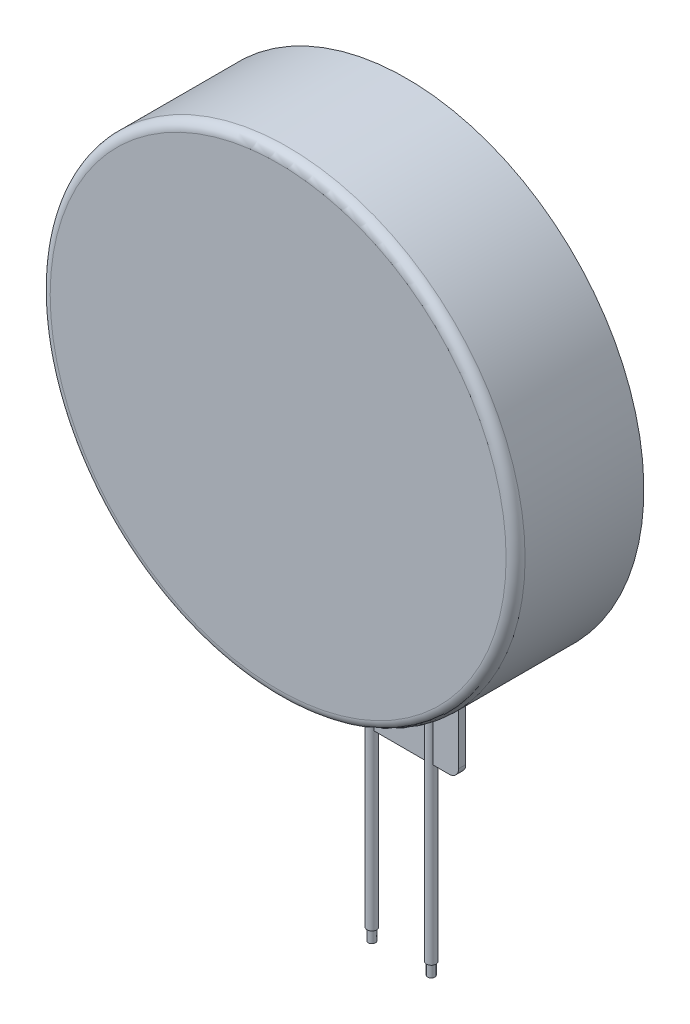
from build123d import *

# Parameters (mm, degrees)
SKETCH1_R                  = 5
BOSS_EXTRUDE1_DEPTH        = 2.7
BOSS_EXTRUDE2_DEPTH        = 0.15
SKETCH4_R                  = 0.101
BOSS_EXTRUDE3_DEPTH        = 3.9
BOSS_EXTRUDE3_DEPTH_BACK   = 2.2
BOSS_EXTRUDE3_2_DEPTH      = 3.9
BOSS_EXTRUDE3_2_DEPTH_BACK = 2.2
FILLET1_R                  = 0.2
FILLET2_R                  = 0.2
SKETCH5_OUTSIDE_W          = 15.81
SKETCH5_OUTSIDE_H          = 8.51
SKETCH5_OUTSIDE_R          = 0.075
CUT_EXTRUDE4_DEPTH         = 0.25


with BuildPart() as part:
    # Sketch1 → Boss-Extrude1 (new body)
    with BuildSketch(Plane.XY):
        Circle(SKETCH1_R)
    extrude(amount=BOSS_EXTRUDE1_DEPTH)

    # Sketch3 → Boss-Extrude2 (add)
    with BuildSketch(Plane(origin=(0, 0, 0), x_dir=(-1, 0, 0), z_dir=(0, 0, -1))):
        Polygon((1.25, -4.841229183), (1.25, -7.091229183), (-1.25, -7.091229183), (-1.25, -4.841229183), (-1.25, -4.179733262), (1.25, -4.179733262), align=None)
    extrude(amount=-BOSS_EXTRUDE2_DEPTH)

    # Fillet1
    fillet1_edges = [part.edges().sort_by_distance(p)[0] for p in [
        (1.25, -7.091229183, 0.075),
        (-1.25, -7.091229183, 0.075),
    ]]
    fillet(fillet1_edges, radius=FILLET1_R)

    # Fillet2
    fillet2_edges = [part.edges().sort_by_distance(p)[0] for p in [
        (-5, 0, 2.7),
    ]]
    fillet(fillet2_edges, radius=FILLET2_R)


with BuildPart() as body_2:
    # Sketch4 → Boss-Extrude3 (new body, two sides)
    with BuildSketch(Plane.XZ.offset(7.091229183)) as boss_extrude3_sk:
        with Locations((-0.625, 0.101)):
            Circle(SKETCH4_R)
    extrude(amount=BOSS_EXTRUDE3_DEPTH)
    extrude(boss_extrude3_sk.sketch, amount=-BOSS_EXTRUDE3_DEPTH_BACK)


with BuildPart() as body_3:
    # Sketch4 → Boss-Extrude3 2 (new body, two sides)
    with BuildSketch(Plane.XZ.offset(7.091229183)) as boss_extrude3_2_sk:
        with Locations((0.625, 0.101)):
            Circle(SKETCH4_R)
    extrude(amount=BOSS_EXTRUDE3_2_DEPTH)
    extrude(boss_extrude3_2_sk.sketch, amount=-BOSS_EXTRUDE3_2_DEPTH_BACK)


with BuildPart() as cut_extrude4_tool:
    # Sketch5 outside → Cut-Extrude4 (new body)
    with BuildSketch(Plane.XZ.offset(10.991229183)):
        with Locations((0, 1.35)):
            Rectangle(SKETCH5_OUTSIDE_W, SKETCH5_OUTSIDE_H)
        with Locations((-0.625, 0.101)):
            Circle(SKETCH5_OUTSIDE_R, mode=Mode.SUBTRACT)
        with Locations((0.625, 0.101)):
            Circle(SKETCH5_OUTSIDE_R, mode=Mode.SUBTRACT)
    extrude(amount=-CUT_EXTRUDE4_DEPTH)


with BuildPart() as body_2_1:
    add(body_2.part)

    # Cut-Extrude4: cut by cut_extrude4_tool
    add(cut_extrude4_tool.part, mode=Mode.SUBTRACT)


with BuildPart() as body_3_1:
    add(body_3.part)

    # Cut-Extrude4: cut by cut_extrude4_tool
    add(cut_extrude4_tool.part, mode=Mode.SUBTRACT)


solid = Compound([part.part, body_2_1.part, body_3_1.part])
